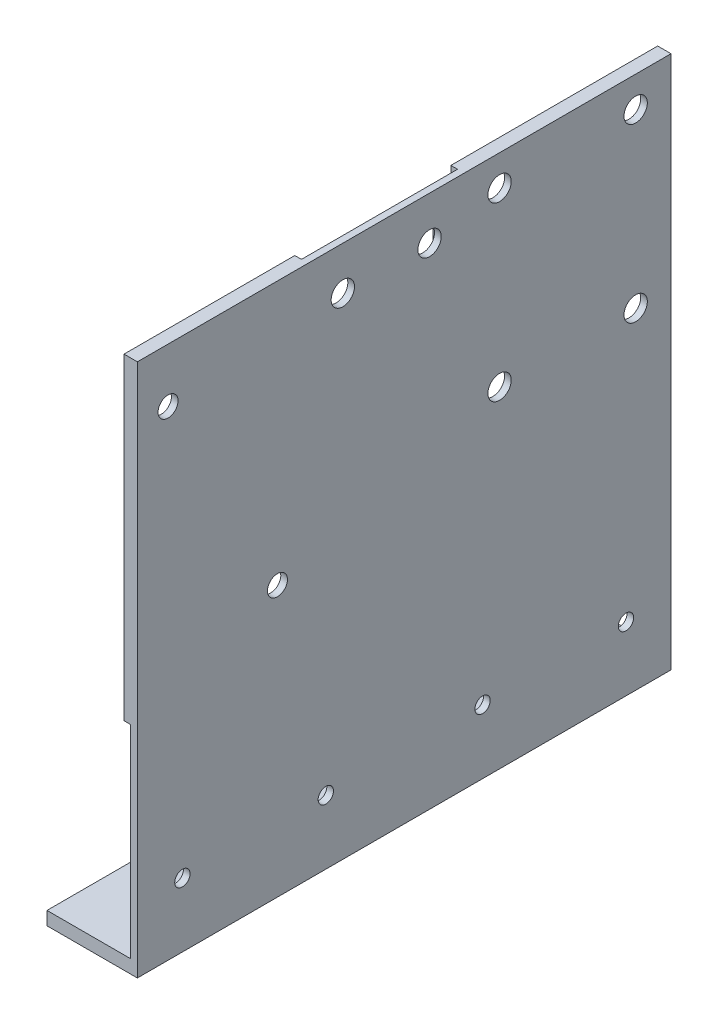
from build123d import *

# Parameters (mm, degrees)
BASE_DEPTH               = 80
SCREW_HOLES_BASE_REACH   = 4
SKETCH3_R                = 1.75
SKETCH6_W                = 31
SKETCH6_H                = 38.5
SKETCH6_W_2              = 27
SKETCH6_H_2              = 34.5
S2MINI_DEPTH             = 1
SKETCH8_R                = 1.75
SCREW_HOLES_S2MINI_DEPTH = 10
SKETCH10_W               = 31
SKETCH10_H               = 23.5
SKETCH10_W_2             = 27
SKETCH10_H_2             = 19.5
MD_DEPTH                 = 1
SKETCH12_R               = 1.15
SCREW_HOLES_MD_DEPTH     = 10
SKETCH14_W               = 25.6
SKETCH14_H               = 47.6
SKETCH14_W_2             = 21.6
SKETCH14_H_2             = 43.6
BC_DEPTH                 = 1
SKETCH16_R               = 1.5
SCREW_HOLES_BC_DEPTH     = 10
SKETCH17_W               = 20
SKETCH17_H               = 27
SKETCH17_W_2             = 18
SKETCH17_H_2             = 25
LA_DEPTH                 = 1
CUT_EXTRUDE6_REACH       = 3
SKETCH18_R               = 1.75


with BuildPart() as part:
    # Sketch1 → Base (new body)
    with BuildSketch(Plane.XY):
        Polygon((0, 0), (0, 2), (12.55, 2), (12.55, 80), (13.55, 80), (13.55, 0), align=None)
    extrude(amount=BASE_DEPTH)

    # Sketch3 → Screw_Holes_Base (cut, up to next)
    with BuildSketch(Plane(origin=(0, 2, 0), x_dir=(1, 0, 0), z_dir=(0, 1, 0)), mode=Mode.PRIVATE) as screw_holes_base_sk1:
        with Locations((6.275, -10)):
            Circle(SKETCH3_R)
    screw_holes_base_tool1 = extrude(screw_holes_base_sk1.sketch, amount=-SCREW_HOLES_BASE_REACH, mode=Mode.PRIVATE) & part.part
    add(screw_holes_base_tool1.solids().sort_by_distance((6.275, 2, 10))[0], mode=Mode.SUBTRACT)
    # Sketch3 → Screw_Holes_Base (cut, up to next)
    with BuildSketch(Plane(origin=(0, 2, 0), x_dir=(1, 0, 0), z_dir=(0, 1, 0)), mode=Mode.PRIVATE) as screw_holes_base_sk2:
        with Locations((6.275, -70)):
            Circle(SKETCH3_R)
    screw_holes_base_tool2 = extrude(screw_holes_base_sk2.sketch, amount=-SCREW_HOLES_BASE_REACH, mode=Mode.PRIVATE) & part.part
    add(screw_holes_base_tool2.solids().sort_by_distance((6.275, 2, 70))[0], mode=Mode.SUBTRACT)

    # Sketch6 → S2Mini (add)
    with BuildSketch(Plane(origin=(12.55, -16.871702151, -147.313128111), x_dir=(0, 0, 1), z_dir=(-1, 0, 0))):
        with Locations((162.813128111, 77.621702151)):
            Rectangle(SKETCH6_W, SKETCH6_H)
        with Locations((162.813128111, 77.621702151)):
            Rectangle(SKETCH6_W_2, SKETCH6_H_2, mode=Mode.SUBTRACT)
    extrude(amount=S2MINI_DEPTH)

    # Sketch8 → Screw_Holes_S2Mini (cut)
    with BuildSketch(Plane(origin=(12.55, 0, 13.55), x_dir=(0, 0, -1), z_dir=(1, 0, 0))):
        with Locations((-12.15, 75.4)):
            Circle(SKETCH8_R)
        with Locations((8.25, 75.4)):
            Circle(SKETCH8_R)
        with Locations((-12.15, 49.6)):
            Circle(SKETCH8_R)
        with Locations((8.25, 49.6)):
            Circle(SKETCH8_R)
    extrude(amount=SCREW_HOLES_S2MINI_DEPTH, mode=Mode.SUBTRACT)

    # Sketch10 → MD (add)
    with BuildSketch(Plane(origin=(12.55, 37.151538962, -62.266989531), x_dir=(0, 0, 1), z_dir=(-1, 0, 0))):
        with Locations((124.766989531, -20.401538962)):
            Rectangle(SKETCH10_W, SKETCH10_H)
        with Locations((124.766989531, -20.401538962)):
            Rectangle(SKETCH10_W_2, SKETCH10_H_2, mode=Mode.SUBTRACT)
    md = extrude(amount=MD_DEPTH)

    # Sketch12 → Screw_Holes_MD (cut)
    with BuildSketch(Plane(origin=(12.55, 0, 13.55), x_dir=(0, 0, -1), z_dir=(1, 0, 0))):
        with Locations((-59.7, 9.6)):
            Circle(SKETCH12_R)
        with Locations((-38.2, 9.6)):
            Circle(SKETCH12_R)
    screw_holes_md = extrude(amount=SCREW_HOLES_MD_DEPTH, mode=Mode.SUBTRACT)

    # Mirror1: MD, Screw_Holes_MD across plane
    add(md.mirror(Plane.XY.offset(40)))
    add(screw_holes_md.mirror(Plane.XY.offset(40)), mode=Mode.SUBTRACT)

    # Sketch14 → BC (add)
    with BuildSketch(Plane(origin=(12.55, 28.832330024, -107.15387648), x_dir=(0, 0, 1), z_dir=(-1, 0, 0))):
        with Locations((174.35387648, 27.367669976)):
            Rectangle(SKETCH14_W, SKETCH14_H)
        with Locations((174.35387648, 27.367669976)):
            Rectangle(SKETCH14_W_2, SKETCH14_H_2, mode=Mode.SUBTRACT)
    extrude(amount=BC_DEPTH)

    # Sketch16 → Screw_Holes_BC (cut)
    with BuildSketch(Plane(origin=(12.55, 0, 13.55), x_dir=(0, 0, -1), z_dir=(1, 0, 0))):
        with Locations((-45.45, 40.5)):
            Circle(SKETCH16_R)
        with Locations((-61.85, 71.9)):
            Circle(SKETCH16_R)
    extrude(amount=SCREW_HOLES_BC_DEPTH, mode=Mode.SUBTRACT)

    # Sketch17 → LA (add)
    with BuildSketch(Plane.ZY.offset(-12.55)):
        with Locations((42.7, 63.5)):
            Rectangle(SKETCH17_W, SKETCH17_H)
        with Locations((42.7, 63.5)):
            Rectangle(SKETCH17_W_2, SKETCH17_H_2, mode=Mode.SUBTRACT)
    extrude(amount=LA_DEPTH)

    # Sketch18 → Cut-Extrude6 (cut, up to next)
    with BuildSketch(Plane.ZY.offset(-12.55), mode=Mode.PRIVATE) as cut_extrude6_sk1:
        with Locations((36.2, 73.5)):
            Circle(SKETCH18_R)
    cut_extrude6_tool1 = extrude(cut_extrude6_sk1.sketch, amount=-CUT_EXTRUDE6_REACH, mode=Mode.PRIVATE) & part.part
    add(cut_extrude6_tool1.solids().sort_by_distance((12.55, 73.5, 36.2))[0], mode=Mode.SUBTRACT)
    # Sketch18 → Cut-Extrude6 (cut, up to next)
    with BuildSketch(Plane.ZY.offset(-12.55), mode=Mode.PRIVATE) as cut_extrude6_sk2:
        with Locations((49.2, 73.5)):
            Circle(SKETCH18_R)
    cut_extrude6_tool2 = extrude(cut_extrude6_sk2.sketch, amount=-CUT_EXTRUDE6_REACH, mode=Mode.PRIVATE) & part.part
    add(cut_extrude6_tool2.solids().sort_by_distance((12.55, 73.5, 49.2))[0], mode=Mode.SUBTRACT)


solid = part.part
